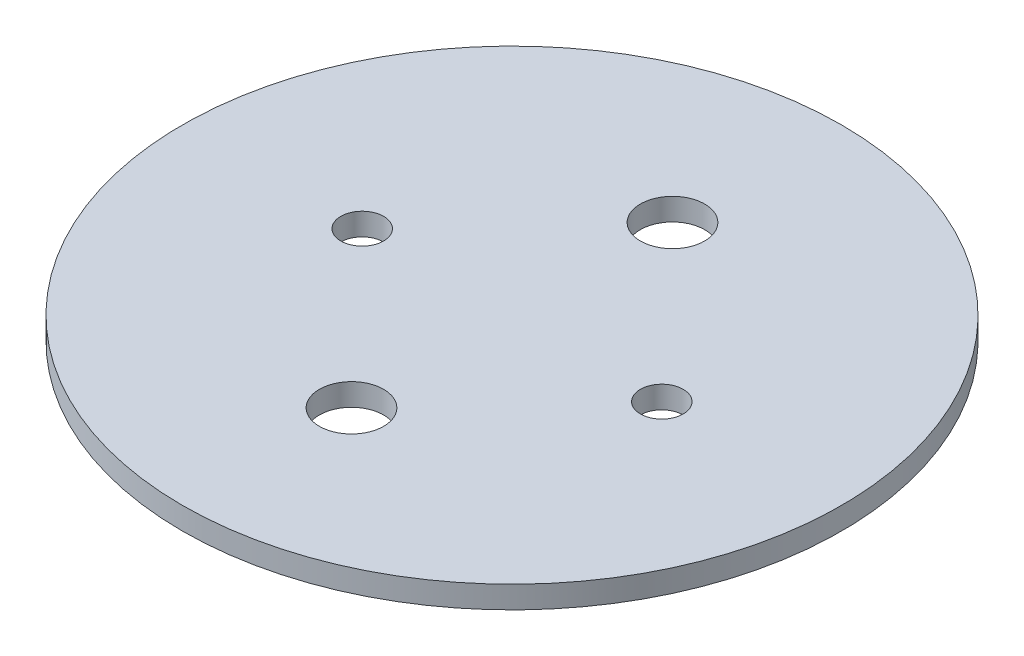
from build123d import *

# Parameters (mm, degrees)
SKETCH1_R           = 48.895
SKETCH1_R_2         = 3.175
SKETCH1_R_3         = 4.7625
BOSS_EXTRUDE1_DEPTH = 3.302


with BuildPart() as part:
    # Sketch1 → Boss-Extrude1 (new body)
    with BuildSketch(Plane(origin=(0, 0, 0), x_dir=(1, 0, 0), z_dir=(0, 1, 0))):
        Circle(SKETCH1_R)
        with Locations((22.225, 0)):
            Circle(SKETCH1_R_2, mode=Mode.SUBTRACT)
        with Locations((-22.225, 0)):
            Circle(SKETCH1_R_2, mode=Mode.SUBTRACT)
        with Locations((0, -23.8125)):
            Circle(SKETCH1_R_3, mode=Mode.SUBTRACT)
        with Locations((0, 23.8125)):
            Circle(SKETCH1_R_3, mode=Mode.SUBTRACT)
    extrude(amount=BOSS_EXTRUDE1_DEPTH)


solid = part.part
